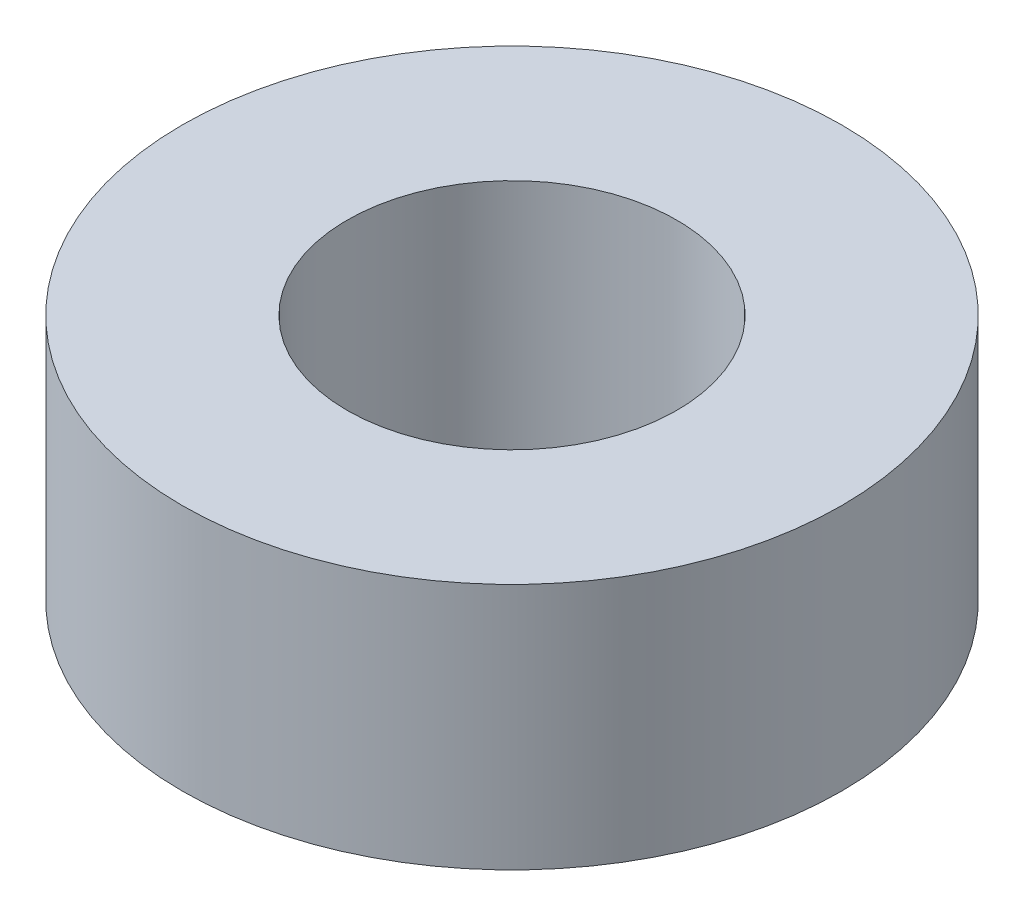
from build123d import *

# Parameters (mm, degrees)
SKETCH_1_R      = 4
SKETCH_1_R_2    = 2
EXTRUDE_1_DEPTH = 3


with BuildPart() as part:
    # 草图1 → 凸台-拉伸1 (new body)
    with BuildSketch(Plane(origin=(0, 0, 0), x_dir=(1, 0, 0), z_dir=(0, 1, 0))):
        Circle(SKETCH_1_R)
        Circle(SKETCH_1_R_2, mode=Mode.SUBTRACT)
    extrude(amount=EXTRUDE_1_DEPTH)


solid = part.part
